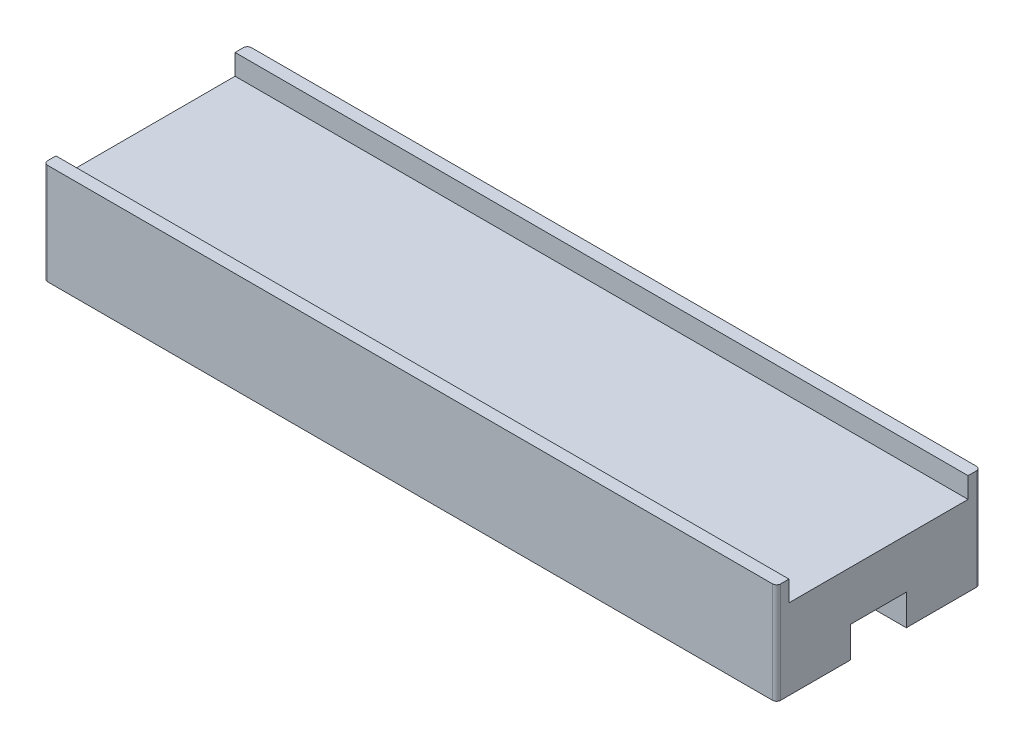
from build123d import *

# Parameters (mm, degrees)
ESQUISSE1_W             = 35.6
ESQUISSE1_H             = 9.9
BOSS_EXTRU_1_DEPTH      = 3.9
ESQUISSE2_W             = 2.7
ESQUISSE2_H             = 1.5
ENL_V_MAT_EXTRU_1_DEPTH = 36.6
ESQUISSE3_W             = 35.6
ESQUISSE3_H             = 0.6
BOSS_EXTRU_2_DEPTH      = 1
CONG_1_R                = 0.2


with BuildPart() as part:
    # Esquisse1 → Boss.-Extru.1 (new body)
    with BuildSketch(Plane(origin=(0, 0, 0), x_dir=(1, 0, 0), z_dir=(0, 1, 0))):
        with Locations((17.8, 4.95)):
            Rectangle(ESQUISSE1_W, ESQUISSE1_H)
    extrude(amount=BOSS_EXTRU_1_DEPTH)

    # Esquisse2 → Enlèv. mat.-Extru.1 (cut, through all)
    with BuildSketch(Plane(origin=(35.6, 0, 0), x_dir=(0, 0, -1), z_dir=(1, 0, 0))):
        with Locations((4.95, 0.75)):
            Rectangle(ESQUISSE2_W, ESQUISSE2_H)
    extrude(amount=-ENL_V_MAT_EXTRU_1_DEPTH, mode=Mode.SUBTRACT)

    # Esquisse3 → Boss.-Extru.2 (add)
    with BuildSketch(Plane(origin=(0, 3.9, 0), x_dir=(1, 0, 0), z_dir=(0, 1, 0))):
        with Locations((17.8, 0.3)):
            Rectangle(ESQUISSE3_W, ESQUISSE3_H)
        with Locations((17.8, 9.6)):
            Rectangle(ESQUISSE3_W, ESQUISSE3_H)
    extrude(amount=BOSS_EXTRU_2_DEPTH)

    # Congé1
    cong_1_edges = [part.edges().sort_by_distance(p)[0] for p in [
        (0, 2.45, -9.9),
        (35.6, 2.45, -9.9),
        (35.6, 2.45, 0),
        (0, 2.45, 0),
    ]]
    fillet(cong_1_edges, radius=CONG_1_R)


solid = part.part
